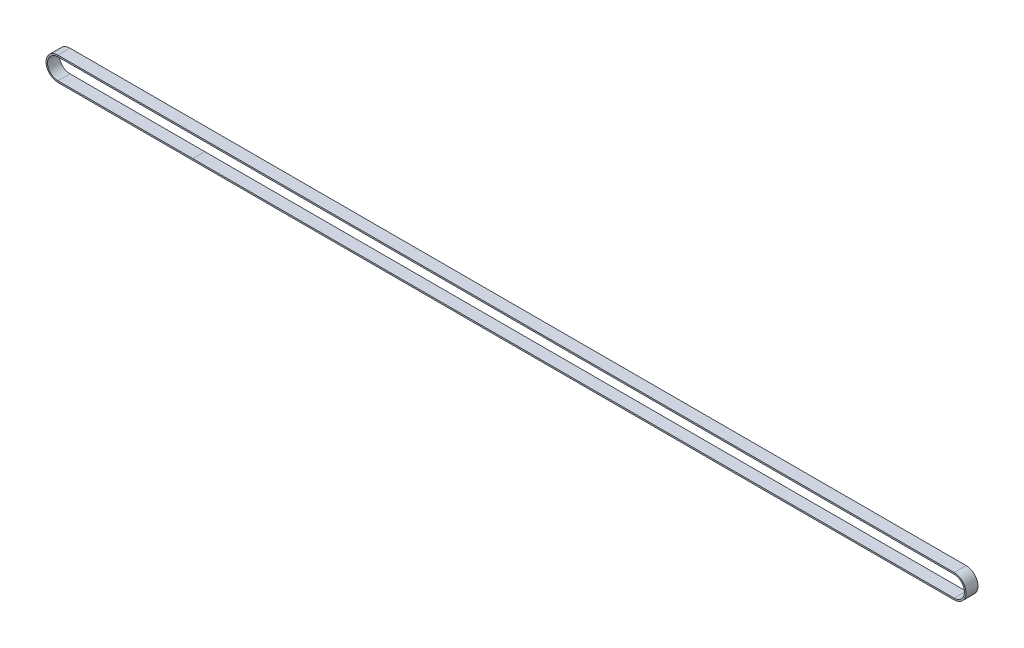
from build123d import *

# Parameters (mm, degrees)
BOSS_EXTRUDE1_DEPTH = 6
CUT_EXTRUDE_2_DEPTH = 7


with BuildPart() as part:
    # Sketch1 → Boss-Extrude1 (new body)
    with BuildSketch(Plane.XY):
        with BuildLine():
            Line((-149.09186475, 9.090711875), (296.90813525, 9.090711875))
            ThreePointArc((296.90813525, 9.090711875), (302.80813525, 3.190711875), (296.90813525, -2.709288125))
            Line((296.90813525, -2.709288125), (-149.09186475, -2.709288125))
            ThreePointArc((-149.09186475, -2.709288125), (-154.99186475, 3.190711875), (-149.09186475, 9.090711875))
        make_face()
        with BuildLine():
            Line((-148.86218671, -1.959304919), (-148.987691743, -1.959304919))
            ThreePointArc((-148.987691743, -1.959304919), (-154.24186475, 3.085711875), (-149.19686475, 8.340711875))
            Line((-149.19686475, 8.340711875), (-148.86218671, 8.34072867))
            ThreePointArc((-148.86218671, 8.34072867), (-148.782434101, 8.302805538), (-148.722766674, 8.237809494))
            ThreePointArc((-148.722766674, 8.237809494), (-148.665742437, 8.11963083), (-148.633605814, 7.992409772))
            ThreePointArc((-148.633605814, 7.992409772), (-148.030521792, 7.471711105), (-147.427440071, 7.992412438))
            ThreePointArc((-147.427440071, 7.992412438), (-147.395304056, 8.119633592), (-147.338280406, 8.237812478))
            ThreePointArc((-147.338280406, 8.237812478), (-147.278614273, 8.302808129), (-147.198941265, 8.340711875))
            Line((-147.198941265, 8.340711875), (-146.862186774, 8.34072867))
            ThreePointArc((-146.862186774, 8.34072867), (-146.782434165, 8.302805538), (-146.722766738, 8.237809494))
            ThreePointArc((-146.722766738, 8.237809494), (-146.665742501, 8.11963083), (-146.633605878, 7.992409772))
            ThreePointArc((-146.633605878, 7.992409772), (-146.030521856, 7.471711105), (-145.427440135, 7.992412438))
            ThreePointArc((-145.427440135, 7.992412438), (-145.395304121, 8.119633592), (-145.33828047, 8.237812478))
            ThreePointArc((-145.33828047, 8.237812478), (-145.278614337, 8.302808129), (-145.198941329, 8.340711875))
            Line((-145.198941329, 8.340711875), (-144.862186838, 8.34072867))
            ThreePointArc((-144.862186838, 8.34072867), (-144.78243423, 8.302805538), (-144.722766802, 8.237809494))
            ThreePointArc((-144.722766802, 8.237809494), (-144.665742565, 8.11963083), (-144.633605942, 7.992409772))
            ThreePointArc((-144.633605942, 7.992409772), (-144.03052192, 7.471711105), (-143.427440199, 7.992412438))
            ThreePointArc((-143.427440199, 7.992412438), (-143.395304185, 8.119633592), (-143.338280535, 8.237812478))
            ThreePointArc((-143.338280535, 8.237812478), (-143.278614401, 8.302808129), (-143.198941393, 8.340711875))
            Line((-143.198941393, 8.340711875), (-142.862186903, 8.34072867))
            ThreePointArc((-142.862186903, 8.34072867), (-142.782434294, 8.302805538), (-142.722766866, 8.237809494))
            ThreePointArc((-142.722766866, 8.237809494), (-142.665742629, 8.11963083), (-142.633606007, 7.992409772))
            ThreePointArc((-142.633606007, 7.992409772), (-142.030521984, 7.471711105), (-141.427440263, 7.992412438))
            ThreePointArc((-141.427440263, 7.992412438), (-141.395304249, 8.119633592), (-141.338280599, 8.237812478))
            ThreePointArc((-141.338280599, 8.237812478), (-141.278614465, 8.302808129), (-141.198941458, 8.340711875))
            Line((-141.198941458, 8.340711875), (-140.862186967, 8.34072867))
            ThreePointArc((-140.862186967, 8.34072867), (-140.782434358, 8.302805538), (-140.722766931, 8.237809494))
            ThreePointArc((-140.722766931, 8.237809494), (-140.665742694, 8.11963083), (-140.633606071, 7.992409772))
            ThreePointArc((-140.633606071, 7.992409772), (-140.030522048, 7.471711105), (-139.427440328, 7.992412438))
            ThreePointArc((-139.427440328, 7.992412438), (-139.395304313, 8.119633592), (-139.338280663, 8.237812478))
            ThreePointArc((-139.338280663, 8.237812478), (-139.27861453, 8.302808129), (-139.198941522, 8.340711875))
            Line((-139.198941522, 8.340711875), (-138.862187031, 8.34072867))
            ThreePointArc((-138.862187031, 8.34072867), (-138.782434422, 8.302805538), (-138.722766995, 8.237809494))
            ThreePointArc((-138.722766995, 8.237809494), (-138.665742758, 8.11963083), (-138.633606135, 7.992409772))
            ThreePointArc((-138.633606135, 7.992409772), (-138.030522113, 7.471711105), (-137.427440392, 7.992412438))
            ThreePointArc((-137.427440392, 7.992412438), (-137.395304377, 8.119633592), (-137.338280727, 8.237812478))
            ThreePointArc((-137.338280727, 8.237812478), (-137.278614594, 8.302808129), (-137.198941586, 8.340711875))
            Line((-137.198941586, 8.340711875), (-136.862187095, 8.34072867))
            ThreePointArc((-136.862187095, 8.34072867), (-136.782434486, 8.302805538), (-136.722767059, 8.237809494))
            ThreePointArc((-136.722767059, 8.237809494), (-136.665742822, 8.11963083), (-136.633606199, 7.992409772))
            ThreePointArc((-136.633606199, 7.992409772), (-136.030522177, 7.471711105), (-135.427440456, 7.992412438))
            ThreePointArc((-135.427440456, 7.992412438), (-135.395304442, 8.119633592), (-135.338280792, 8.237812478))
            ThreePointArc((-135.338280792, 8.237812478), (-135.278614658, 8.302808129), (-135.19894165, 8.340711875))
            Line((-135.19894165, 8.340711875), (-134.86218716, 8.34072867))
            ThreePointArc((-134.86218716, 8.34072867), (-134.782434551, 8.302805538), (-134.722767123, 8.237809494))
            ThreePointArc((-134.722767123, 8.237809494), (-134.665742886, 8.11963083), (-134.633606264, 7.992409772))
            ThreePointArc((-134.633606264, 7.992409772), (-134.030522241, 7.471711105), (-133.42744052, 7.992412438))
            ThreePointArc((-133.42744052, 7.992412438), (-133.395304506, 8.119633592), (-133.338280856, 8.237812478))
            ThreePointArc((-133.338280856, 8.237812478), (-133.278614722, 8.302808129), (-133.198941715, 8.340711875))
            Line((-133.198941715, 8.340711875), (-132.862187224, 8.34072867))
            ThreePointArc((-132.862187224, 8.34072867), (-132.782434615, 8.302805538), (-132.722767187, 8.237809494))
            ThreePointArc((-132.722767187, 8.237809494), (-132.665742951, 8.11963083), (-132.633606328, 7.992409772))
            ThreePointArc((-132.633606328, 7.992409772), (-132.030522305, 7.471711105), (-131.427440585, 7.992412438))
            ThreePointArc((-131.427440585, 7.992412438), (-131.39530457, 8.119633592), (-131.33828092, 8.237812478))
            ThreePointArc((-131.33828092, 8.237812478), (-131.278614786, 8.302808129), (-131.198941779, 8.340711875))
            Line((-131.198941779, 8.340711875), (-130.862187288, 8.34072867))
            ThreePointArc((-130.862187288, 8.34072867), (-130.782434679, 8.302805538), (-130.722767252, 8.237809494))
            ThreePointArc((-130.722767252, 8.237809494), (-130.665743015, 8.11963083), (-130.633606392, 7.992409772))
            ThreePointArc((-130.633606392, 7.992409772), (-130.03052237, 7.471711105), (-129.427440649, 7.992412438))
            ThreePointArc((-129.427440649, 7.992412438), (-129.395304634, 8.119633592), (-129.338280984, 8.237812478))
            ThreePointArc((-129.338280984, 8.237812478), (-129.278614851, 8.302808129), (-129.198941843, 8.340711875))
            Line((-129.198941843, 8.340711875), (-128.862187352, 8.34072867))
            ThreePointArc((-128.862187352, 8.34072867), (-128.782434743, 8.302805538), (-128.722767316, 8.237809494))
            ThreePointArc((-128.722767316, 8.237809494), (-128.665743079, 8.11963083), (-128.633606456, 7.992409772))
            ThreePointArc((-128.633606456, 7.992409772), (-128.030522434, 7.471711105), (-127.427440713, 7.992412438))
            ThreePointArc((-127.427440713, 7.992412438), (-127.395304699, 8.119633592), (-127.338281048, 8.237812478))
            ThreePointArc((-127.338281048, 8.237812478), (-127.278614915, 8.302808129), (-127.198941907, 8.340711875))
            Line((-127.198941907, 8.340711875), (-126.862187417, 8.34072867))
            ThreePointArc((-126.862187417, 8.34072867), (-126.782434808, 8.302805538), (-126.72276738, 8.237809494))
            ThreePointArc((-126.72276738, 8.237809494), (-126.665743143, 8.11963083), (-126.63360652, 7.992409772))
            ThreePointArc((-126.63360652, 7.992409772), (-126.030522498, 7.471711105), (-125.427440777, 7.992412438))
            ThreePointArc((-125.427440777, 7.992412438), (-125.395304763, 8.119633592), (-125.338281113, 8.237812478))
            ThreePointArc((-125.338281113, 8.237812478), (-125.278614979, 8.302808129), (-125.198941972, 8.340711875))
            Line((-125.198941972, 8.340711875), (-124.862187481, 8.34072867))
            ThreePointArc((-124.862187481, 8.34072867), (-124.782434872, 8.302805538), (-124.722767444, 8.237809494))
            ThreePointArc((-124.722767444, 8.237809494), (-124.665743208, 8.11963083), (-124.633606585, 7.992409772))
            ThreePointArc((-124.633606585, 7.992409772), (-124.030522562, 7.471711105), (-123.427440841, 7.992412438))
            ThreePointArc((-123.427440841, 7.992412438), (-123.395304827, 8.119633592), (-123.338281177, 8.237812478))
            ThreePointArc((-123.338281177, 8.237812478), (-123.278615043, 8.302808129), (-123.198942036, 8.340711875))
            Line((-123.198942036, 8.340711875), (-122.862187545, 8.34072867))
            ThreePointArc((-122.862187545, 8.34072867), (-122.782434936, 8.302805538), (-122.722767509, 8.237809494))
            ThreePointArc((-122.722767509, 8.237809494), (-122.665743272, 8.11963083), (-122.633606649, 7.992409772))
            ThreePointArc((-122.633606649, 7.992409772), (-122.030522627, 7.471711105), (-121.427440906, 7.992412438))
            ThreePointArc((-121.427440906, 7.992412438), (-121.395304891, 8.119633592), (-121.338281241, 8.237812478))
            ThreePointArc((-121.338281241, 8.237812478), (-121.278615108, 8.302808129), (-121.1989421, 8.340711875))
            Line((-121.1989421, 8.340711875), (-120.862187609, 8.34072867))
            ThreePointArc((-120.862187609, 8.34072867), (-120.782435, 8.302805538), (-120.722767573, 8.237809494))
            ThreePointArc((-120.722767573, 8.237809494), (-120.665743336, 8.11963083), (-120.633606713, 7.992409772))
            ThreePointArc((-120.633606713, 7.992409772), (-120.030522691, 7.471711105), (-119.42744097, 7.992412438))
            ThreePointArc((-119.42744097, 7.992412438), (-119.395304956, 8.119633592), (-119.338281305, 8.237812478))
            ThreePointArc((-119.338281305, 8.237812478), (-119.278615172, 8.302808129), (-119.198942164, 8.340711875))
            Line((-119.198942164, 8.340711875), (-118.862187673, 8.34072867))
            ThreePointArc((-118.862187673, 8.34072867), (-118.782435064, 8.302805538), (-118.722767637, 8.237809494))
            ThreePointArc((-118.722767637, 8.237809494), (-118.6657434, 8.11963083), (-118.633606777, 7.992409772))
            ThreePointArc((-118.633606777, 7.992409772), (-118.030522755, 7.471711105), (-117.427441034, 7.992412438))
            ThreePointArc((-117.427441034, 7.992412438), (-117.39530502, 8.119633592), (-117.33828137, 8.237812478))
            ThreePointArc((-117.33828137, 8.237812478), (-117.278615236, 8.302808129), (-117.198942228, 8.340711875))
            Line((-117.198942228, 8.340711875), (-116.862187738, 8.34072867))
            ThreePointArc((-116.862187738, 8.34072867), (-116.782435129, 8.302805538), (-116.722767701, 8.237809494))
            ThreePointArc((-116.722767701, 8.237809494), (-116.665743464, 8.11963083), (-116.633606842, 7.992409772))
            ThreePointArc((-116.633606842, 7.992409772), (-116.030522819, 7.471711105), (-115.427441098, 7.992412438))
            ThreePointArc((-115.427441098, 7.992412438), (-115.395305084, 8.119633592), (-115.338281434, 8.237812478))
            ThreePointArc((-115.338281434, 8.237812478), (-115.2786153, 8.302808129), (-115.198942293, 8.340711875))
            Line((-115.198942293, 8.340711875), (-114.862187802, 8.34072867))
            ThreePointArc((-114.862187802, 8.34072867), (-114.782435193, 8.302805538), (-114.722767766, 8.237809494))
            ThreePointArc((-114.722767766, 8.237809494), (-114.665743529, 8.11963083), (-114.633606906, 7.992409772))
            ThreePointArc((-114.633606906, 7.992409772), (-114.030522883, 7.471711105), (-113.427441163, 7.992412438))
            ThreePointArc((-113.427441163, 7.992412438), (-113.395305148, 8.119633592), (-113.338281498, 8.237812478))
            ThreePointArc((-113.338281498, 8.237812478), (-113.278615364, 8.302808129), (-113.198942357, 8.340711875))
            Line((-113.198942357, 8.340711875), (-112.862187866, 8.34072867))
            ThreePointArc((-112.862187866, 8.34072867), (-112.782435257, 8.302805538), (-112.72276783, 8.237809494))
            ThreePointArc((-112.72276783, 8.237809494), (-112.665743593, 8.11963083), (-112.63360697, 7.992409772))
            ThreePointArc((-112.63360697, 7.992409772), (-112.030522948, 7.471711105), (-111.427441227, 7.992412438))
            ThreePointArc((-111.427441227, 7.992412438), (-111.395305212, 8.119633592), (-111.338281562, 8.237812478))
            ThreePointArc((-111.338281562, 8.237812478), (-111.278615429, 8.302808129), (-111.198942421, 8.340711875))
            Line((-111.198942421, 8.340711875), (-110.86218793, 8.34072867))
            ThreePointArc((-110.86218793, 8.34072867), (-110.782435321, 8.302805538), (-110.722767894, 8.237809494))
            ThreePointArc((-110.722767894, 8.237809494), (-110.665743657, 8.11963083), (-110.633607034, 7.992409772))
            ThreePointArc((-110.633607034, 7.992409772), (-110.030523012, 7.471711105), (-109.427441291, 7.992412438))
            ThreePointArc((-109.427441291, 7.992412438), (-109.395305277, 8.119633592), (-109.338281627, 8.237812478))
            ThreePointArc((-109.338281627, 8.237812478), (-109.278615493, 8.302808129), (-109.198942485, 8.340711875))
            Line((-109.198942485, 8.340711875), (-108.862187995, 8.34072867))
            ThreePointArc((-108.862187995, 8.34072867), (-108.782435386, 8.302805538), (-108.722767958, 8.237809494))
            ThreePointArc((-108.722767958, 8.237809494), (-108.665743721, 8.11963083), (-108.633607098, 7.992409772))
            ThreePointArc((-108.633607098, 7.992409772), (-108.030523076, 7.471711105), (-107.427441355, 7.992412438))
            ThreePointArc((-107.427441355, 7.992412438), (-107.395305341, 8.119633592), (-107.338281691, 8.237812478))
            ThreePointArc((-107.338281691, 8.237812478), (-107.278615557, 8.302808129), (-107.19894255, 8.340711875))
            Line((-107.19894255, 8.340711875), (-106.862188059, 8.34072867))
            ThreePointArc((-106.862188059, 8.34072867), (-106.78243545, 8.302805538), (-106.722768022, 8.237809494))
            ThreePointArc((-106.722768022, 8.237809494), (-106.665743786, 8.11963083), (-106.633607163, 7.992409772))
            ThreePointArc((-106.633607163, 7.992409772), (-106.03052314, 7.471711105), (-105.42744142, 7.992412438))
            ThreePointArc((-105.42744142, 7.992412438), (-105.395305405, 8.119633592), (-105.338281755, 8.237812478))
            ThreePointArc((-105.338281755, 8.237812478), (-105.278615621, 8.302808129), (-105.198942614, 8.340711875))
            Line((-105.198942614, 8.340711875), (-104.862188123, 8.34072867))
            ThreePointArc((-104.862188123, 8.34072867), (-104.782435514, 8.302805538), (-104.722768087, 8.237809494))
            ThreePointArc((-104.722768087, 8.237809494), (-104.66574385, 8.11963083), (-104.633607227, 7.992409772))
            ThreePointArc((-104.633607227, 7.992409772), (-104.030523205, 7.471711105), (-103.427441484, 7.992412438))
            ThreePointArc((-103.427441484, 7.992412438), (-103.395305469, 8.119633592), (-103.338281819, 8.237812478))
            ThreePointArc((-103.338281819, 8.237812478), (-103.278615686, 8.302808129), (-103.198942678, 8.340711875))
            Line((-103.198942678, 8.340711875), (-102.862188187, 8.34072867))
            ThreePointArc((-102.862188187, 8.34072867), (-102.782435578, 8.302805538), (-102.722768151, 8.237809494))
            ThreePointArc((-102.722768151, 8.237809494), (-102.665743914, 8.11963083), (-102.633607291, 7.992409772))
            ThreePointArc((-102.633607291, 7.992409772), (-102.030523269, 7.471711105), (-101.427441548, 7.992412438))
            ThreePointArc((-101.427441548, 7.992412438), (-101.395305534, 8.119633592), (-101.338281883, 8.237812478))
            ThreePointArc((-101.338281883, 8.237812478), (-101.27861575, 8.302808129), (-101.198942742, 8.340711875))
            Line((-101.198942742, 8.340711875), (-100.862188251, 8.34072867))
            ThreePointArc((-100.862188251, 8.34072867), (-100.782435643, 8.302805538), (-100.722768215, 8.237809494))
            ThreePointArc((-100.722768215, 8.237809494), (-100.665743978, 8.11963083), (-100.633607355, 7.992409772))
            ThreePointArc((-100.633607355, 7.992409772), (-100.030523333, 7.471711105), (-99.427441612, 7.992412438))
            ThreePointArc((-99.427441612, 7.992412438), (-99.395305598, 8.119633592), (-99.338281948, 8.237812478))
            ThreePointArc((-99.338281948, 8.237812478), (-99.278615814, 8.302808129), (-99.198942806, 8.340711875))
            Line((-99.198942806, 8.340711875), (-98.862188316, 8.34072867))
            ThreePointArc((-98.862188316, 8.34072867), (-98.782435707, 8.302805538), (-98.722768279, 8.237809494))
            ThreePointArc((-98.722768279, 8.237809494), (-98.665744042, 8.11963083), (-98.63360742, 7.992409772))
            ThreePointArc((-98.63360742, 7.992409772), (-98.030523397, 7.471711105), (-97.427441676, 7.992412438))
            ThreePointArc((-97.427441676, 7.992412438), (-97.395305662, 8.119633592), (-97.338282012, 8.237812478))
            ThreePointArc((-97.338282012, 8.237812478), (-97.278615878, 8.302808129), (-97.198942871, 8.340711875))
            Line((-97.198942871, 8.340711875), (-96.86218838, 8.34072867))
            ThreePointArc((-96.86218838, 8.34072867), (-96.782435771, 8.302805538), (-96.722768344, 8.237809494))
            ThreePointArc((-96.722768344, 8.237809494), (-96.665744107, 8.11963083), (-96.633607484, 7.992409772))
            ThreePointArc((-96.633607484, 7.992409772), (-96.030523461, 7.471711105), (-95.427441741, 7.992412438))
            ThreePointArc((-95.427441741, 7.992412438), (-95.395305726, 8.119633592), (-95.338282076, 8.237812478))
            ThreePointArc((-95.338282076, 8.237812478), (-95.278615943, 8.302808129), (-95.198942935, 8.340711875))
            Line((-95.198942935, 8.340711875), (-94.862188444, 8.34072867))
            ThreePointArc((-94.862188444, 8.34072867), (-94.782435835, 8.302805538), (-94.722768408, 8.237809494))
            ThreePointArc((-94.722768408, 8.237809494), (-94.665744171, 8.11963083), (-94.633607548, 7.992409772))
            ThreePointArc((-94.633607548, 7.992409772), (-94.030523526, 7.471711105), (-93.427441805, 7.992412438))
            ThreePointArc((-93.427441805, 7.992412438), (-93.39530579, 8.119633592), (-93.33828214, 8.237812478))
            ThreePointArc((-93.33828214, 8.237812478), (-93.278616007, 8.302808129), (-93.198942999, 8.340711875))
            Line((-93.198942999, 8.340711875), (-92.862188508, 8.34072867))
            ThreePointArc((-92.862188508, 8.34072867), (-92.782435899, 8.302805538), (-92.722768472, 8.237809494))
            ThreePointArc((-92.722768472, 8.237809494), (-92.665744235, 8.11963083), (-92.633607612, 7.992409772))
            ThreePointArc((-92.633607612, 7.992409772), (-92.03052359, 7.471711105), (-91.427441869, 7.992412438))
            ThreePointArc((-91.427441869, 7.992412438), (-91.395305855, 8.119633592), (-91.338282205, 8.237812478))
            ThreePointArc((-91.338282205, 8.237812478), (-91.278616071, 8.302808129), (-91.198943063, 8.340711875))
            Line((-91.198943063, 8.340711875), (-90.862188573, 8.34072867))
            ThreePointArc((-90.862188573, 8.34072867), (-90.782435964, 8.302805538), (-90.722768536, 8.237809494))
            ThreePointArc((-90.722768536, 8.237809494), (-90.665744299, 8.11963083), (-90.633607677, 7.992409772))
            ThreePointArc((-90.633607677, 7.992409772), (-90.030523654, 7.471711105), (-89.427441933, 7.992412438))
            ThreePointArc((-89.427441933, 7.992412438), (-89.395305919, 8.119633592), (-89.338282269, 8.237812478))
            ThreePointArc((-89.338282269, 8.237812478), (-89.278616135, 8.302808129), (-89.198943128, 8.340711875))
            Line((-89.198943128, 8.340711875), (-88.862188637, 8.34072867))
            ThreePointArc((-88.862188637, 8.34072867), (-88.782436028, 8.302805538), (-88.7227686, 8.237809494))
            ThreePointArc((-88.7227686, 8.237809494), (-88.665744364, 8.11963083), (-88.633607741, 7.992409772))
            ThreePointArc((-88.633607741, 7.992409772), (-88.030523718, 7.471711105), (-87.427441998, 7.992412438))
            ThreePointArc((-87.427441998, 7.992412438), (-87.395305983, 8.119633592), (-87.338282333, 8.237812478))
            ThreePointArc((-87.338282333, 8.237812478), (-87.278616199, 8.302808129), (-87.198943192, 8.340711875))
            Line((-87.198943192, 8.340711875), (-86.862188701, 8.34072867))
            ThreePointArc((-86.862188701, 8.34072867), (-86.782436092, 8.302805538), (-86.722768665, 8.237809494))
            ThreePointArc((-86.722768665, 8.237809494), (-86.665744428, 8.11963083), (-86.633607805, 7.992409772))
            ThreePointArc((-86.633607805, 7.992409772), (-86.030523783, 7.471711105), (-85.427442062, 7.992412438))
            ThreePointArc((-85.427442062, 7.992412438), (-85.395306047, 8.119633592), (-85.338282397, 8.237812478))
            ThreePointArc((-85.338282397, 8.237812478), (-85.278616264, 8.302808129), (-85.198943256, 8.340711875))
            Line((-85.198943256, 8.340711875), (-84.862188765, 8.34072867))
            ThreePointArc((-84.862188765, 8.34072867), (-84.782436156, 8.302805538), (-84.722768729, 8.237809494))
            ThreePointArc((-84.722768729, 8.237809494), (-84.665744492, 8.11963083), (-84.633607869, 7.992409772))
            ThreePointArc((-84.633607869, 7.992409772), (-84.030523847, 7.471711105), (-83.427442126, 7.992412438))
            ThreePointArc((-83.427442126, 7.992412438), (-83.395306112, 8.119633592), (-83.338282461, 8.237812478))
            ThreePointArc((-83.338282461, 8.237812478), (-83.278616328, 8.302808129), (-83.19894332, 8.340711875))
            Line((-83.19894332, 8.340711875), (296.90813525, 8.340711875))
            ThreePointArc((296.90813525, 8.340711875), (302.05813525, 3.190711875), (296.90813525, -1.959288125))
            Line((296.90813525, -1.959288125), (-83.19894332, -1.959288125))
            ThreePointArc((-83.19894332, -1.959288125), (-83.278616328, -1.921384378), (-83.338282461, -1.856388727))
            ThreePointArc((-83.338282461, -1.856388727), (-83.395306112, -1.738209842), (-83.427442126, -1.610988687))
            ThreePointArc((-83.427442126, -1.610988687), (-84.030523847, -1.090287354), (-84.633607869, -1.610986021))
            ThreePointArc((-84.633607869, -1.610986021), (-84.665744492, -1.73820708), (-84.722768729, -1.856385743))
            ThreePointArc((-84.722768729, -1.856385743), (-84.782436156, -1.921381787), (-84.862188765, -1.959304919))
            Line((-84.862188765, -1.959304919), (-85.198943256, -1.959288125))
            ThreePointArc((-85.198943256, -1.959288125), (-85.278616264, -1.921384378), (-85.338282397, -1.856388727))
            ThreePointArc((-85.338282397, -1.856388727), (-85.395306047, -1.738209842), (-85.427442062, -1.610988687))
            ThreePointArc((-85.427442062, -1.610988687), (-86.030523783, -1.090287354), (-86.633607805, -1.610986021))
            ThreePointArc((-86.633607805, -1.610986021), (-86.665744428, -1.73820708), (-86.722768665, -1.856385743))
            ThreePointArc((-86.722768665, -1.856385743), (-86.782436092, -1.921381787), (-86.862188701, -1.959304919))
            Line((-86.862188701, -1.959304919), (-87.198943192, -1.959288125))
            ThreePointArc((-87.198943192, -1.959288125), (-87.278616199, -1.921384378), (-87.338282333, -1.856388727))
            ThreePointArc((-87.338282333, -1.856388727), (-87.395305983, -1.738209842), (-87.427441998, -1.610988687))
            ThreePointArc((-87.427441998, -1.610988687), (-88.030523718, -1.090287354), (-88.633607741, -1.610986021))
            ThreePointArc((-88.633607741, -1.610986021), (-88.665744364, -1.73820708), (-88.7227686, -1.856385743))
            ThreePointArc((-88.7227686, -1.856385743), (-88.782436028, -1.921381787), (-88.862188637, -1.959304919))
            Line((-88.862188637, -1.959304919), (-89.198943128, -1.959288125))
            ThreePointArc((-89.198943128, -1.959288125), (-89.278616135, -1.921384378), (-89.338282269, -1.856388727))
            ThreePointArc((-89.338282269, -1.856388727), (-89.395305919, -1.738209842), (-89.427441933, -1.610988687))
            ThreePointArc((-89.427441933, -1.610988687), (-90.030523654, -1.090287354), (-90.633607677, -1.610986021))
            ThreePointArc((-90.633607677, -1.610986021), (-90.665744299, -1.73820708), (-90.722768536, -1.856385743))
            ThreePointArc((-90.722768536, -1.856385743), (-90.782435964, -1.921381787), (-90.862188573, -1.959304919))
            Line((-90.862188573, -1.959304919), (-91.198943063, -1.959288125))
            ThreePointArc((-91.198943063, -1.959288125), (-91.278616071, -1.921384378), (-91.338282205, -1.856388727))
            ThreePointArc((-91.338282205, -1.856388727), (-91.395305855, -1.738209842), (-91.427441869, -1.610988687))
            ThreePointArc((-91.427441869, -1.610988687), (-92.03052359, -1.090287354), (-92.633607612, -1.610986021))
            ThreePointArc((-92.633607612, -1.610986021), (-92.665744235, -1.73820708), (-92.722768472, -1.856385743))
            ThreePointArc((-92.722768472, -1.856385743), (-92.782435899, -1.921381787), (-92.862188508, -1.959304919))
            Line((-92.862188508, -1.959304919), (-93.198942999, -1.959288125))
            ThreePointArc((-93.198942999, -1.959288125), (-93.278616007, -1.921384378), (-93.33828214, -1.856388727))
            ThreePointArc((-93.33828214, -1.856388727), (-93.39530579, -1.738209842), (-93.427441805, -1.610988687))
            ThreePointArc((-93.427441805, -1.610988687), (-94.030523526, -1.090287354), (-94.633607548, -1.610986021))
            ThreePointArc((-94.633607548, -1.610986021), (-94.665744171, -1.73820708), (-94.722768408, -1.856385743))
            ThreePointArc((-94.722768408, -1.856385743), (-94.782435835, -1.921381787), (-94.862188444, -1.959304919))
            Line((-94.862188444, -1.959304919), (-95.198942935, -1.959288125))
            ThreePointArc((-95.198942935, -1.959288125), (-95.278615943, -1.921384378), (-95.338282076, -1.856388727))
            ThreePointArc((-95.338282076, -1.856388727), (-95.395305726, -1.738209842), (-95.427441741, -1.610988687))
            ThreePointArc((-95.427441741, -1.610988687), (-96.030523461, -1.090287354), (-96.633607484, -1.610986021))
            ThreePointArc((-96.633607484, -1.610986021), (-96.665744107, -1.73820708), (-96.722768344, -1.856385743))
            ThreePointArc((-96.722768344, -1.856385743), (-96.782435771, -1.921381787), (-96.86218838, -1.959304919))
            Line((-96.86218838, -1.959304919), (-97.198942871, -1.959288125))
            ThreePointArc((-97.198942871, -1.959288125), (-97.278615878, -1.921384378), (-97.338282012, -1.856388727))
            ThreePointArc((-97.338282012, -1.856388727), (-97.395305662, -1.738209842), (-97.427441676, -1.610988687))
            ThreePointArc((-97.427441676, -1.610988687), (-98.030523397, -1.090287354), (-98.63360742, -1.610986021))
            ThreePointArc((-98.63360742, -1.610986021), (-98.665744042, -1.73820708), (-98.722768279, -1.856385743))
            ThreePointArc((-98.722768279, -1.856385743), (-98.782435707, -1.921381787), (-98.862188316, -1.959304919))
            Line((-98.862188316, -1.959304919), (-99.198942806, -1.959288125))
            ThreePointArc((-99.198942806, -1.959288125), (-99.278615814, -1.921384378), (-99.338281948, -1.856388727))
            ThreePointArc((-99.338281948, -1.856388727), (-99.395305598, -1.738209842), (-99.427441612, -1.610988687))
            ThreePointArc((-99.427441612, -1.610988687), (-100.030523333, -1.090287354), (-100.633607355, -1.610986021))
            ThreePointArc((-100.633607355, -1.610986021), (-100.665743978, -1.73820708), (-100.722768215, -1.856385743))
            ThreePointArc((-100.722768215, -1.856385743), (-100.782435643, -1.921381787), (-100.862188251, -1.959304919))
            Line((-100.862188251, -1.959304919), (-101.198942742, -1.959288125))
            ThreePointArc((-101.198942742, -1.959288125), (-101.27861575, -1.921384378), (-101.338281883, -1.856388727))
            ThreePointArc((-101.338281883, -1.856388727), (-101.395305534, -1.738209842), (-101.427441548, -1.610988687))
            ThreePointArc((-101.427441548, -1.610988687), (-102.030523269, -1.090287354), (-102.633607291, -1.610986021))
            ThreePointArc((-102.633607291, -1.610986021), (-102.665743914, -1.73820708), (-102.722768151, -1.856385743))
            ThreePointArc((-102.722768151, -1.856385743), (-102.782435578, -1.921381787), (-102.862188187, -1.959304919))
            Line((-102.862188187, -1.959304919), (-103.198942678, -1.959288125))
            ThreePointArc((-103.198942678, -1.959288125), (-103.278615686, -1.921384378), (-103.338281819, -1.856388727))
            ThreePointArc((-103.338281819, -1.856388727), (-103.395305469, -1.738209842), (-103.427441484, -1.610988687))
            ThreePointArc((-103.427441484, -1.610988687), (-104.030523205, -1.090287354), (-104.633607227, -1.610986021))
            ThreePointArc((-104.633607227, -1.610986021), (-104.66574385, -1.73820708), (-104.722768087, -1.856385743))
            ThreePointArc((-104.722768087, -1.856385743), (-104.782435514, -1.921381787), (-104.862188123, -1.959304919))
            Line((-104.862188123, -1.959304919), (-105.198942614, -1.959288125))
            ThreePointArc((-105.198942614, -1.959288125), (-105.278615621, -1.921384378), (-105.338281755, -1.856388727))
            ThreePointArc((-105.338281755, -1.856388727), (-105.395305405, -1.738209842), (-105.42744142, -1.610988687))
            ThreePointArc((-105.42744142, -1.610988687), (-106.03052314, -1.090287354), (-106.633607163, -1.610986021))
            ThreePointArc((-106.633607163, -1.610986021), (-106.665743786, -1.73820708), (-106.722768022, -1.856385743))
            ThreePointArc((-106.722768022, -1.856385743), (-106.78243545, -1.921381787), (-106.862188059, -1.959304919))
            Line((-106.862188059, -1.959304919), (-107.19894255, -1.959288125))
            ThreePointArc((-107.19894255, -1.959288125), (-107.278615557, -1.921384378), (-107.338281691, -1.856388727))
            ThreePointArc((-107.338281691, -1.856388727), (-107.395305341, -1.738209842), (-107.427441355, -1.610988687))
            ThreePointArc((-107.427441355, -1.610988687), (-108.030523076, -1.090287354), (-108.633607098, -1.610986021))
            ThreePointArc((-108.633607098, -1.610986021), (-108.665743721, -1.73820708), (-108.722767958, -1.856385743))
            ThreePointArc((-108.722767958, -1.856385743), (-108.782435386, -1.921381787), (-108.862187995, -1.959304919))
            Line((-108.862187995, -1.959304919), (-109.198942485, -1.959288125))
            ThreePointArc((-109.198942485, -1.959288125), (-109.278615493, -1.921384378), (-109.338281627, -1.856388727))
            ThreePointArc((-109.338281627, -1.856388727), (-109.395305277, -1.738209842), (-109.427441291, -1.610988687))
            ThreePointArc((-109.427441291, -1.610988687), (-110.030523012, -1.090287354), (-110.633607034, -1.610986021))
            ThreePointArc((-110.633607034, -1.610986021), (-110.665743657, -1.73820708), (-110.722767894, -1.856385743))
            ThreePointArc((-110.722767894, -1.856385743), (-110.782435321, -1.921381787), (-110.86218793, -1.959304919))
            Line((-110.86218793, -1.959304919), (-111.198942421, -1.959288125))
            ThreePointArc((-111.198942421, -1.959288125), (-111.278615429, -1.921384378), (-111.338281562, -1.856388727))
            ThreePointArc((-111.338281562, -1.856388727), (-111.395305212, -1.738209842), (-111.427441227, -1.610988687))
            ThreePointArc((-111.427441227, -1.610988687), (-112.030522948, -1.090287354), (-112.63360697, -1.610986021))
            ThreePointArc((-112.63360697, -1.610986021), (-112.665743593, -1.73820708), (-112.72276783, -1.856385743))
            ThreePointArc((-112.72276783, -1.856385743), (-112.782435257, -1.921381787), (-112.862187866, -1.959304919))
            Line((-112.862187866, -1.959304919), (-113.198942357, -1.959288125))
            ThreePointArc((-113.198942357, -1.959288125), (-113.278615364, -1.921384378), (-113.338281498, -1.856388727))
            ThreePointArc((-113.338281498, -1.856388727), (-113.395305148, -1.738209842), (-113.427441163, -1.610988687))
            ThreePointArc((-113.427441163, -1.610988687), (-114.030522883, -1.090287354), (-114.633606906, -1.610986021))
            ThreePointArc((-114.633606906, -1.610986021), (-114.665743529, -1.73820708), (-114.722767766, -1.856385743))
            ThreePointArc((-114.722767766, -1.856385743), (-114.782435193, -1.921381787), (-114.862187802, -1.959304919))
            Line((-114.862187802, -1.959304919), (-115.198942293, -1.959288125))
            ThreePointArc((-115.198942293, -1.959288125), (-115.2786153, -1.921384378), (-115.338281434, -1.856388727))
            ThreePointArc((-115.338281434, -1.856388727), (-115.395305084, -1.738209842), (-115.427441098, -1.610988687))
            ThreePointArc((-115.427441098, -1.610988687), (-116.030522819, -1.090287354), (-116.633606842, -1.610986021))
            ThreePointArc((-116.633606842, -1.610986021), (-116.665743464, -1.73820708), (-116.722767701, -1.856385743))
            ThreePointArc((-116.722767701, -1.856385743), (-116.782435129, -1.921381787), (-116.862187738, -1.959304919))
            Line((-116.862187738, -1.959304919), (-117.198942228, -1.959288125))
            ThreePointArc((-117.198942228, -1.959288125), (-117.278615236, -1.921384378), (-117.33828137, -1.856388727))
            ThreePointArc((-117.33828137, -1.856388727), (-117.39530502, -1.738209842), (-117.427441034, -1.610988687))
            ThreePointArc((-117.427441034, -1.610988687), (-118.030522755, -1.090287354), (-118.633606777, -1.610986021))
            ThreePointArc((-118.633606777, -1.610986021), (-118.6657434, -1.73820708), (-118.722767637, -1.856385743))
            ThreePointArc((-118.722767637, -1.856385743), (-118.782435064, -1.921381787), (-118.862187673, -1.959304919))
            Line((-118.862187673, -1.959304919), (-119.198942164, -1.959288125))
            ThreePointArc((-119.198942164, -1.959288125), (-119.278615172, -1.921384378), (-119.338281305, -1.856388727))
            ThreePointArc((-119.338281305, -1.856388727), (-119.395304956, -1.738209842), (-119.42744097, -1.610988687))
            ThreePointArc((-119.42744097, -1.610988687), (-120.030522691, -1.090287354), (-120.633606713, -1.610986021))
            ThreePointArc((-120.633606713, -1.610986021), (-120.665743336, -1.73820708), (-120.722767573, -1.856385743))
            ThreePointArc((-120.722767573, -1.856385743), (-120.782435, -1.921381787), (-120.862187609, -1.959304919))
            Line((-120.862187609, -1.959304919), (-121.1989421, -1.959288125))
            ThreePointArc((-121.1989421, -1.959288125), (-121.278615108, -1.921384378), (-121.338281241, -1.856388727))
            ThreePointArc((-121.338281241, -1.856388727), (-121.395304891, -1.738209842), (-121.427440906, -1.610988687))
            ThreePointArc((-121.427440906, -1.610988687), (-122.030522627, -1.090287354), (-122.633606649, -1.610986021))
            ThreePointArc((-122.633606649, -1.610986021), (-122.665743272, -1.73820708), (-122.722767509, -1.856385743))
            ThreePointArc((-122.722767509, -1.856385743), (-122.782434936, -1.921381787), (-122.862187545, -1.959304919))
            Line((-122.862187545, -1.959304919), (-123.198942036, -1.959288125))
            ThreePointArc((-123.198942036, -1.959288125), (-123.278615043, -1.921384378), (-123.338281177, -1.856388727))
            ThreePointArc((-123.338281177, -1.856388727), (-123.395304827, -1.738209842), (-123.427440841, -1.610988687))
            ThreePointArc((-123.427440841, -1.610988687), (-124.030522562, -1.090287354), (-124.633606585, -1.610986021))
            ThreePointArc((-124.633606585, -1.610986021), (-124.665743208, -1.73820708), (-124.722767444, -1.856385743))
            ThreePointArc((-124.722767444, -1.856385743), (-124.782434872, -1.921381787), (-124.862187481, -1.959304919))
            Line((-124.862187481, -1.959304919), (-125.198941972, -1.959288125))
            ThreePointArc((-125.198941972, -1.959288125), (-125.278614979, -1.921384378), (-125.338281113, -1.856388727))
            ThreePointArc((-125.338281113, -1.856388727), (-125.395304763, -1.738209842), (-125.427440777, -1.610988687))
            ThreePointArc((-125.427440777, -1.610988687), (-126.030522498, -1.090287354), (-126.63360652, -1.610986021))
            ThreePointArc((-126.63360652, -1.610986021), (-126.665743143, -1.73820708), (-126.72276738, -1.856385743))
            ThreePointArc((-126.72276738, -1.856385743), (-126.782434808, -1.921381787), (-126.862187417, -1.959304919))
            Line((-126.862187417, -1.959304919), (-127.198941907, -1.959288125))
            ThreePointArc((-127.198941907, -1.959288125), (-127.278614915, -1.921384378), (-127.338281048, -1.856388727))
            ThreePointArc((-127.338281048, -1.856388727), (-127.395304699, -1.738209842), (-127.427440713, -1.610988687))
            ThreePointArc((-127.427440713, -1.610988687), (-128.030522434, -1.090287354), (-128.633606456, -1.610986021))
            ThreePointArc((-128.633606456, -1.610986021), (-128.665743079, -1.73820708), (-128.722767316, -1.856385743))
            ThreePointArc((-128.722767316, -1.856385743), (-128.782434743, -1.921381787), (-128.862187352, -1.959304919))
            Line((-128.862187352, -1.959304919), (-129.198941843, -1.959288125))
            ThreePointArc((-129.198941843, -1.959288125), (-129.278614851, -1.921384378), (-129.338280984, -1.856388727))
            ThreePointArc((-129.338280984, -1.856388727), (-129.395304634, -1.738209842), (-129.427440649, -1.610988687))
            ThreePointArc((-129.427440649, -1.610988687), (-130.03052237, -1.090287354), (-130.633606392, -1.610986021))
            ThreePointArc((-130.633606392, -1.610986021), (-130.665743015, -1.73820708), (-130.722767252, -1.856385743))
            ThreePointArc((-130.722767252, -1.856385743), (-130.782434679, -1.921381787), (-130.862187288, -1.959304919))
            Line((-130.862187288, -1.959304919), (-131.198941779, -1.959288125))
            ThreePointArc((-131.198941779, -1.959288125), (-131.278614786, -1.921384378), (-131.33828092, -1.856388727))
            ThreePointArc((-131.33828092, -1.856388727), (-131.39530457, -1.738209842), (-131.427440585, -1.610988687))
            ThreePointArc((-131.427440585, -1.610988687), (-132.030522305, -1.090287354), (-132.633606328, -1.610986021))
            ThreePointArc((-132.633606328, -1.610986021), (-132.665742951, -1.73820708), (-132.722767187, -1.856385743))
            ThreePointArc((-132.722767187, -1.856385743), (-132.782434615, -1.921381787), (-132.862187224, -1.959304919))
            Line((-132.862187224, -1.959304919), (-133.198941715, -1.959288125))
            ThreePointArc((-133.198941715, -1.959288125), (-133.278614722, -1.921384378), (-133.338280856, -1.856388727))
            ThreePointArc((-133.338280856, -1.856388727), (-133.395304506, -1.738209842), (-133.42744052, -1.610988687))
            ThreePointArc((-133.42744052, -1.610988687), (-134.030522241, -1.090287354), (-134.633606264, -1.610986021))
            ThreePointArc((-134.633606264, -1.610986021), (-134.665742886, -1.73820708), (-134.722767123, -1.856385743))
            ThreePointArc((-134.722767123, -1.856385743), (-134.782434551, -1.921381787), (-134.86218716, -1.959304919))
            Line((-134.86218716, -1.959304919), (-135.19894165, -1.959288125))
            ThreePointArc((-135.19894165, -1.959288125), (-135.278614658, -1.921384378), (-135.338280792, -1.856388727))
            ThreePointArc((-135.338280792, -1.856388727), (-135.395304442, -1.738209842), (-135.427440456, -1.610988687))
            ThreePointArc((-135.427440456, -1.610988687), (-136.030522177, -1.090287354), (-136.633606199, -1.610986021))
            ThreePointArc((-136.633606199, -1.610986021), (-136.665742822, -1.73820708), (-136.722767059, -1.856385743))
            ThreePointArc((-136.722767059, -1.856385743), (-136.782434486, -1.921381787), (-136.862187095, -1.959304919))
            Line((-136.862187095, -1.959304919), (-137.198941586, -1.959288125))
            ThreePointArc((-137.198941586, -1.959288125), (-137.278614594, -1.921384378), (-137.338280727, -1.856388727))
            ThreePointArc((-137.338280727, -1.856388727), (-137.395304377, -1.738209842), (-137.427440392, -1.610988687))
            ThreePointArc((-137.427440392, -1.610988687), (-138.030522113, -1.090287354), (-138.633606135, -1.610986021))
            ThreePointArc((-138.633606135, -1.610986021), (-138.665742758, -1.73820708), (-138.722766995, -1.856385743))
            ThreePointArc((-138.722766995, -1.856385743), (-138.782434422, -1.921381787), (-138.862187031, -1.959304919))
            Line((-138.862187031, -1.959304919), (-139.198941522, -1.959288125))
            ThreePointArc((-139.198941522, -1.959288125), (-139.27861453, -1.921384378), (-139.338280663, -1.856388727))
            ThreePointArc((-139.338280663, -1.856388727), (-139.395304313, -1.738209842), (-139.427440328, -1.610988687))
            ThreePointArc((-139.427440328, -1.610988687), (-140.030522048, -1.090287354), (-140.633606071, -1.610986021))
            ThreePointArc((-140.633606071, -1.610986021), (-140.665742694, -1.73820708), (-140.722766931, -1.856385743))
            ThreePointArc((-140.722766931, -1.856385743), (-140.782434358, -1.921381787), (-140.862186967, -1.959304919))
            Line((-140.862186967, -1.959304919), (-141.198941458, -1.959288125))
            ThreePointArc((-141.198941458, -1.959288125), (-141.278614465, -1.921384378), (-141.338280599, -1.856388727))
            ThreePointArc((-141.338280599, -1.856388727), (-141.395304249, -1.738209842), (-141.427440263, -1.610988687))
            ThreePointArc((-141.427440263, -1.610988687), (-142.030521984, -1.090287354), (-142.633606007, -1.610986021))
            ThreePointArc((-142.633606007, -1.610986021), (-142.665742629, -1.73820708), (-142.722766866, -1.856385743))
            ThreePointArc((-142.722766866, -1.856385743), (-142.782434294, -1.921381787), (-142.862186903, -1.959304919))
            Line((-142.862186903, -1.959304919), (-143.198941393, -1.959288125))
            ThreePointArc((-143.198941393, -1.959288125), (-143.278614401, -1.921384378), (-143.338280535, -1.856388727))
            ThreePointArc((-143.338280535, -1.856388727), (-143.395304185, -1.738209842), (-143.427440199, -1.610988687))
            ThreePointArc((-143.427440199, -1.610988687), (-144.03052192, -1.090287354), (-144.633605942, -1.610986021))
            ThreePointArc((-144.633605942, -1.610986021), (-144.665742565, -1.73820708), (-144.722766802, -1.856385743))
            ThreePointArc((-144.722766802, -1.856385743), (-144.78243423, -1.921381787), (-144.862186838, -1.959304919))
            Line((-144.862186838, -1.959304919), (-145.198941329, -1.959288125))
            ThreePointArc((-145.198941329, -1.959288125), (-145.278614337, -1.921384378), (-145.33828047, -1.856388727))
            ThreePointArc((-145.33828047, -1.856388727), (-145.395304121, -1.738209842), (-145.427440135, -1.610988687))
            ThreePointArc((-145.427440135, -1.610988687), (-146.030521856, -1.090287354), (-146.633605878, -1.610986021))
            ThreePointArc((-146.633605878, -1.610986021), (-146.665742501, -1.73820708), (-146.722766738, -1.856385743))
            ThreePointArc((-146.722766738, -1.856385743), (-146.782434165, -1.921381787), (-146.862186774, -1.959304919))
            Line((-146.862186774, -1.959304919), (-147.198941265, -1.959288125))
            ThreePointArc((-147.198941265, -1.959288125), (-147.278614273, -1.921384378), (-147.338280406, -1.856388727))
            ThreePointArc((-147.338280406, -1.856388727), (-147.395304056, -1.738209842), (-147.427440071, -1.610988687))
            ThreePointArc((-147.427440071, -1.610988687), (-148.030521792, -1.090287354), (-148.633605814, -1.610986021))
            ThreePointArc((-148.633605814, -1.610986021), (-148.665742437, -1.73820708), (-148.722766674, -1.856385743))
            ThreePointArc((-148.722766674, -1.856385743), (-148.782434101, -1.921381787), (-148.86218671, -1.959304919))
        make_face(mode=Mode.SUBTRACT)
    extrude(amount=BOSS_EXTRUDE1_DEPTH)

    # 草图1 → 切除-拉伸2 (cut, through all)
    with BuildSketch(Plane.XY.offset(6)):
        Polygon((-81.966358792, 8.340711875), (-149.19686475, 8.340711875), (-149.09186475, -1.960358402), (-81.966358792, -1.959288125), align=None)
    extrude(amount=-CUT_EXTRUDE_2_DEPTH, mode=Mode.SUBTRACT)


solid = part.part
